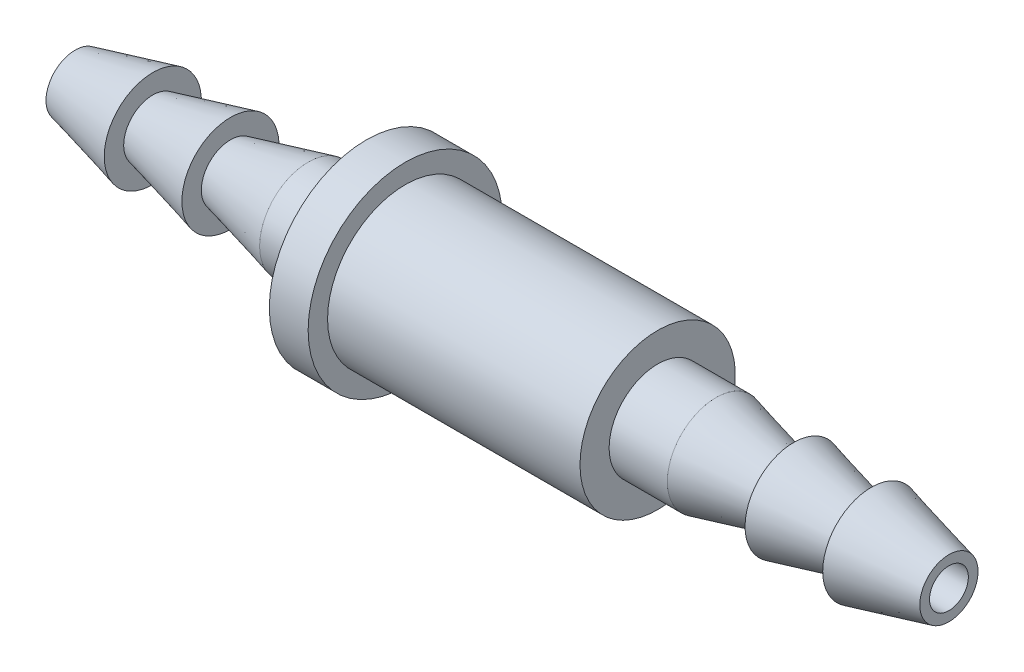
from build123d import *

# Parameters (mm, degrees)
SKETCH_2_R          = 1
CUT_EXTRUDE_1_DEPTH = 46


with BuildPart() as part:
    # Эскиз1 → Повернуть1 (revolve)
    with BuildSketch(Plane.XY):
        Polygon((-30, 2.5), (-33, 2.5), (-37, 1.5), (-37, 2.5), (-41, 1.5), (-41, 2.5), (-45, 1.5), (-45, 0), (0, 0), (0, 1.5), (-4, 2.5), (-4, 1.5), (-8, 2.5), (-8, 1.5), (-12, 2.5), (-15, 2.5), (-15, 4), (-28, 4), (-28, 5), (-30, 5), align=None)
    revolve(axis=Axis((-45, 0, 0), (1, 0, 0)))

    # Эскиз2 → Вырез-Вытянуть1 (cut, through all)
    with BuildSketch(Plane.ZY.offset(45)):
        Circle(SKETCH_2_R)
    extrude(amount=-CUT_EXTRUDE_1_DEPTH, mode=Mode.SUBTRACT)


solid = part.part
